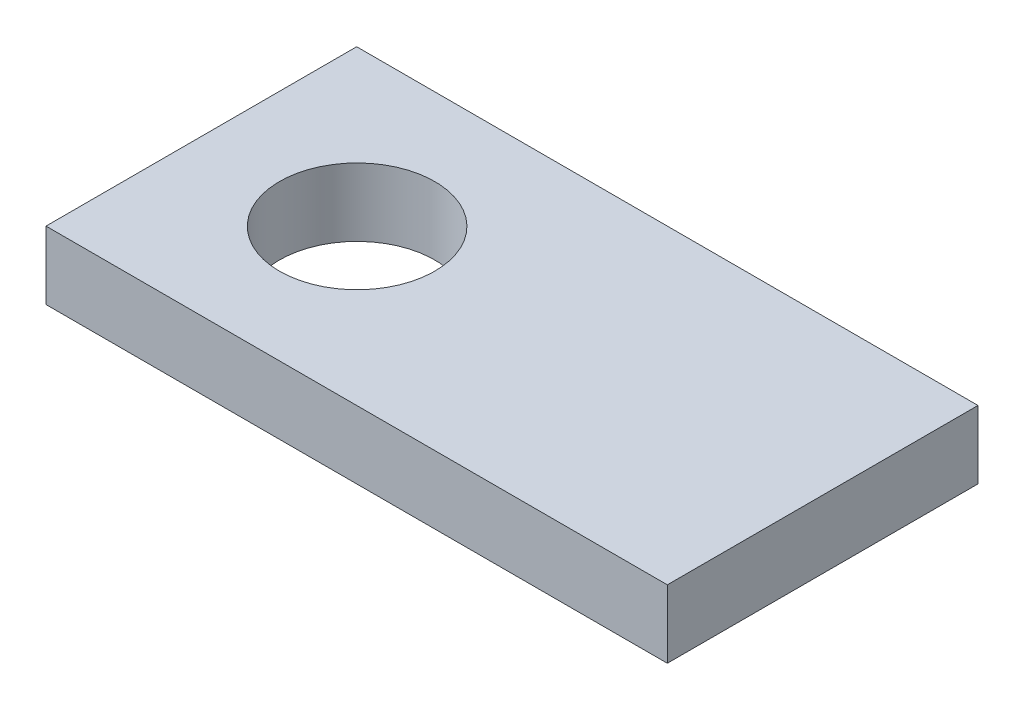
from build123d import *

# Parameters (mm, degrees)
SKETCH1_W           = 101.6
SKETCH1_H           = 50.8
SKETCH1_R           = 12.7
BOSS_EXTRUDE1_DEPTH = 11.1125


with BuildPart() as part:
    # Sketch1 → Boss-Extrude1 (new body)
    with BuildSketch(Plane(origin=(0, 0, 0), x_dir=(1, 0, 0), z_dir=(0, 1, 0))):
        Rectangle(SKETCH1_W, SKETCH1_H)
        with Locations((-25.325740296, 0)):
            Circle(SKETCH1_R, mode=Mode.SUBTRACT)
    extrude(amount=BOSS_EXTRUDE1_DEPTH)


solid = part.part
